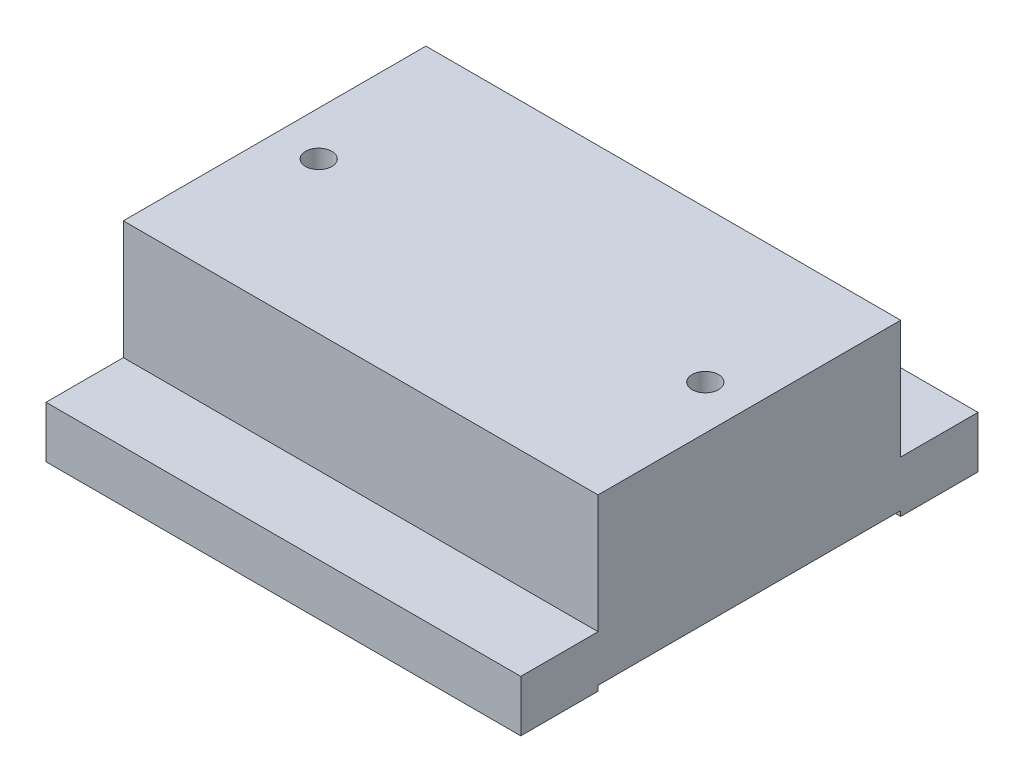
from build123d import *

# Parameters (mm, degrees)
SKETCH1_W                   = 92.1
SKETCH1_H                   = 88.7
BOSS_EXTRUDE1_DEPTH         = 10
SKETCH2_W                   = 92.1
SKETCH2_H                   = 58.7
BOSS_EXTRUDE2_DEPTH         = 22.986
SKETCH16_W                  = 92.1
SKETCH16_H                  = 58.7
CUT_EXTRUDE2_DEPTH          = 1
F_1_4_20_TAPPED_HOLE1_D     = 5.1054
F_1_4_20_TAPPED_HOLE1_DEPTH = 16.51
F_1_4_20_TAPPED_HOLE1_TIP   = 1.533816902


with BuildPart() as part:
    # Sketch1 → Boss-Extrude1 (new body)
    with BuildSketch(Plane(origin=(0, 0, 0), x_dir=(1, 0, 0), z_dir=(0, 1, 0))):
        Rectangle(SKETCH1_W, SKETCH1_H)
    extrude(amount=BOSS_EXTRUDE1_DEPTH)

    # Sketch2 → Boss-Extrude2 (add)
    with BuildSketch(Plane(origin=(0, 10, 0), x_dir=(1, 0, 0), z_dir=(0, 1, 0))):
        Rectangle(SKETCH2_W, SKETCH2_H)
    extrude(amount=BOSS_EXTRUDE2_DEPTH)

    # Sketch16 → Cut-Extrude2 (cut)
    with BuildSketch(Plane.XZ):
        Rectangle(SKETCH16_W, SKETCH16_H)
    extrude(amount=-CUT_EXTRUDE2_DEPTH, mode=Mode.SUBTRACT)

    # 1/4-20 Tapped Hole1
    with Locations(Plane(origin=(0, 32.986, 0), x_dir=(-1, 0, 0), z_dir=(0, 1, 0))):
        with Locations((37.5, 0), (-37.5, 0)):
            Hole(F_1_4_20_TAPPED_HOLE1_D / 2, depth=F_1_4_20_TAPPED_HOLE1_DEPTH)
            with Locations((0, 0, -(F_1_4_20_TAPPED_HOLE1_DEPTH + F_1_4_20_TAPPED_HOLE1_TIP / 2))):  # 118° drill point
                Cone(0, F_1_4_20_TAPPED_HOLE1_D / 2, F_1_4_20_TAPPED_HOLE1_TIP, mode=Mode.SUBTRACT)


solid = part.part
